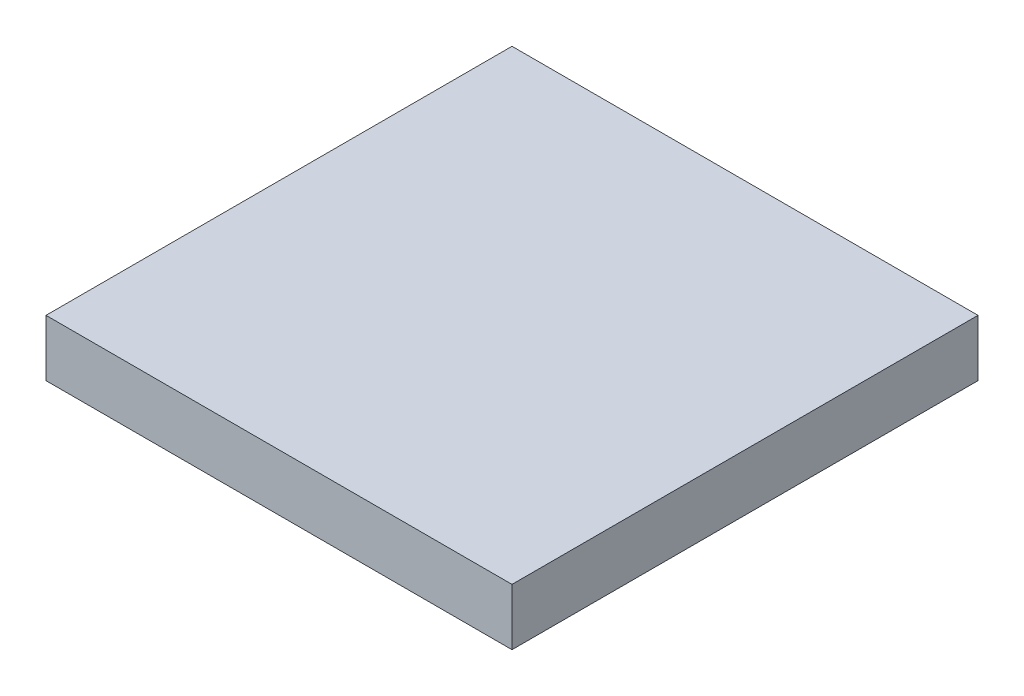
from build123d import *

# Parameters (mm, degrees)
SKETCH1_W           = 7
SKETCH1_H           = 7
BOSS_EXTRUDE1_DEPTH = 0.85


with BuildPart() as part:
    # Sketch1 → Boss-Extrude1 (new body)
    with BuildSketch(Plane(origin=(0, 0, 0), x_dir=(1, 0, 0), z_dir=(0, 1, 0))):
        with Locations((3.5, 3.5)):
            Rectangle(SKETCH1_W, SKETCH1_H)
    extrude(amount=BOSS_EXTRUDE1_DEPTH)


solid = part.part
